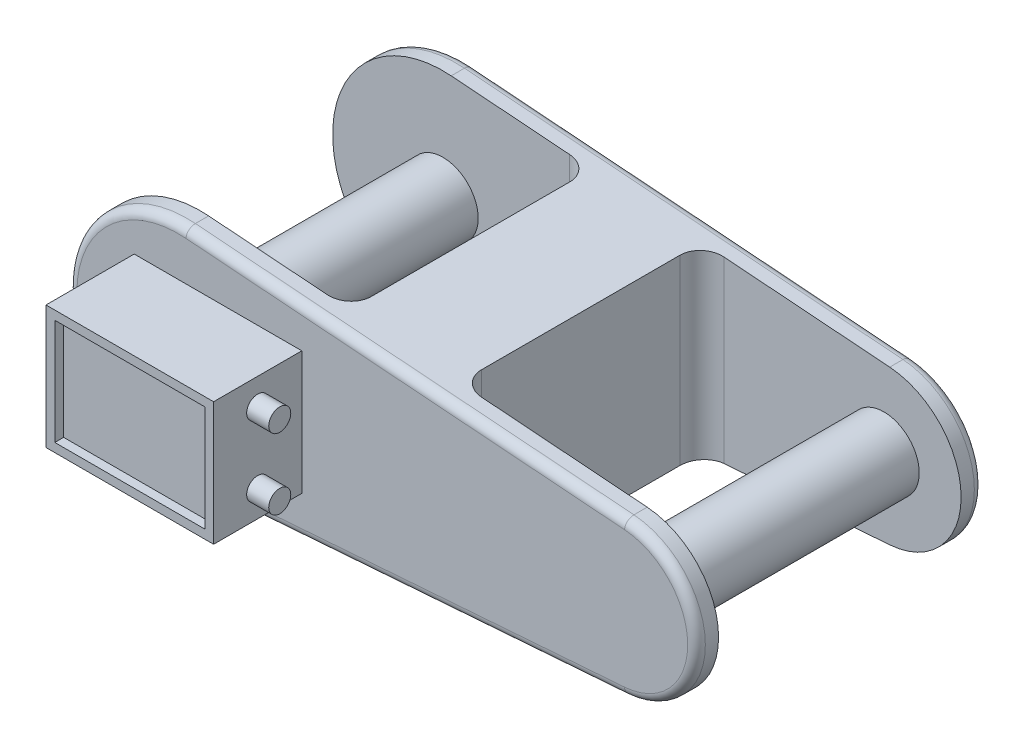
from build123d import *

# Parameters (mm, degrees)
Y_KSEKLIK_EKSTR_ZYON1_DEPTH = 32.5
IZIM3_W                     = 58.75
IZIM3_H                     = 55
KES_EKSTR_ZYON1_DEPTH       = 26
KES_EKSTR_ZYON1_DEPTH_BACK  = 26
IZIM4_R                     = 8
Y_KSEKLIK_EKSTR_ZYON2_DEPTH = 32.5
RADYUS1_R                   = 5
IZIM5_W                     = 38
IZIM5_H                     = 28
Y_KSEKLIK_EKSTR_ZYON3_DEPTH = 20
IZIM6_R                     = 2.5
Y_KSEKLIK_EKSTR_ZYON4_DEPTH = 5
IZIM7_W                     = 34
IZIM7_H                     = 24
KES_EKSTR_ZYON2_DEPTH       = 2
RADYUS2_R                   = 2


with BuildPart() as part:
    # Çizim1 → Yükseklik-Ekstrüzyon1 (new body, symmetric)
    with BuildSketch(Plane.XY):
        with BuildLine():
            Line((1.875, 24.929588344), (101.3125, 17.450711841))
            ThreePointArc((101.3125, 17.450711841), (117.5, 0), (101.3125, -17.450711841))
            Line((101.3125, -17.450711841), (1.875, -24.929588344))
            ThreePointArc((1.875, -24.929588344), (-25, 0), (1.875, 24.929588344))
        make_face()
    extrude(amount=Y_KSEKLIK_EKSTR_ZYON1_DEPTH, both=True)

    # Çizim3 → Kes-Ekstrüzyon1 (cut, two sides)
    with BuildSketch(Plane(origin=(0, 0, 0), x_dir=(1, 0, 0), z_dir=(0, 1, 0))) as kes_ekstr_zyon1_sk:
        with Locations((4.375, 0)):
            Rectangle(IZIM3_W, IZIM3_H)
        with Locations((88.125, 0)):
            Rectangle(IZIM3_W, IZIM3_H)
    extrude(amount=KES_EKSTR_ZYON1_DEPTH, mode=Mode.SUBTRACT)
    extrude(kes_ekstr_zyon1_sk.sketch, amount=-KES_EKSTR_ZYON1_DEPTH_BACK, mode=Mode.SUBTRACT)

    # Çizim4 → Yükseklik-Ekstrüzyon2 (add, symmetric)
    with BuildSketch(Plane.XY):
        Circle(IZIM4_R)
        with Locations((100, 0)):
            Circle(IZIM4_R)
    extrude(amount=Y_KSEKLIK_EKSTR_ZYON2_DEPTH, both=True)

    # Radyus1
    radyus1_edges = [part.edges().sort_by_distance(p)[0] for p in [
        (33.75, 0, -27.5),
        (33.75, 0, 27.5),
        (58.75, 0, 27.5),
        (58.75, 0, -27.5),
    ]]
    fillet(radyus1_edges, radius=RADYUS1_R)

    # Radyus2
    radyus2_edges = [part.edges().sort_by_distance(p)[0] for p in [
        (117.5, 0, 32.5),
        (51.59375, 21.190150092, 32.5),
        (-25, 0, 32.5),
        (51.59375, 21.190150092, -32.5),
        (117.5, 0, -32.5),
        (51.59375, -21.190150092, -32.5),
        (-25, 0, -32.5),
        (51.59375, -21.190150092, 32.5),
    ]]
    fillet(radyus2_edges, radius=RADYUS2_R)


with BuildPart() as body_2:
    # Çizim5 → Yükseklik-Ekstrüzyon3 (new body)
    with BuildSketch(Plane.XY.offset(32.5)):
        with Locations((9, 0)):
            Rectangle(IZIM5_W, IZIM5_H)
    extrude(amount=Y_KSEKLIK_EKSTR_ZYON3_DEPTH)

    # Çizim6 → Yükseklik-Ekstrüzyon4 (add)
    with BuildSketch(Plane(origin=(28, 0, 0), x_dir=(0, 0, -1), z_dir=(1, 0, 0))):
        with Locations((-42.5, 8)):
            Circle(IZIM6_R)
        with Locations((-42.5, -8)):
            Circle(IZIM6_R)
    extrude(amount=Y_KSEKLIK_EKSTR_ZYON4_DEPTH)

    # Çizim7 → Kes-Ekstrüzyon2 (cut)
    with BuildSketch(Plane.XY.offset(52.5)):
        with Locations((9, 0)):
            Rectangle(IZIM7_W, IZIM7_H)
    extrude(amount=-KES_EKSTR_ZYON2_DEPTH, mode=Mode.SUBTRACT)


solid = Compound([part.part, body_2.part])
